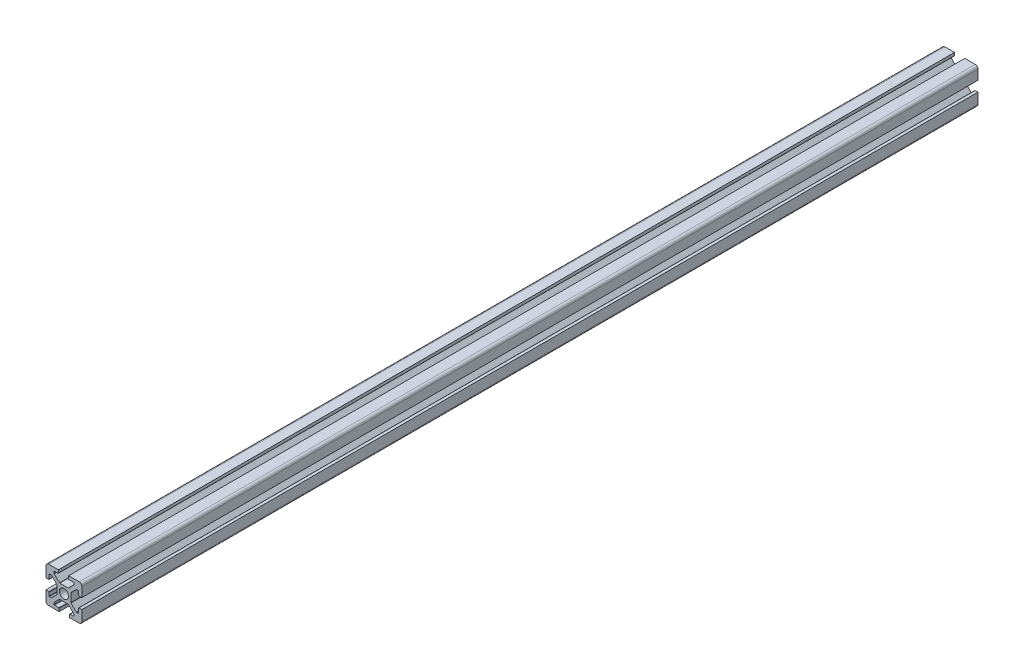
from build123d import *

# Parameters (mm, degrees)
SKETCH1_R           = 2.55
BOSS_EXTRUDE1_DEPTH = 500


with BuildPart() as part:
    # Sketch1 → Boss-Extrude1 (new body)
    with BuildSketch(Plane.XY):
        with BuildLine():
            Line((-8.5, -10), (-2.647623804, -10))
            Line((-2.647623804, -10), (-2.647623804, -8.45))
            ThreePointArc((-2.647623804, -8.45), (-2.720847109, -8.273223305), (-2.897623804, -8.2))
            Line((-2.897623804, -8.2), (-5.25, -8.2))
            ThreePointArc((-5.25, -8.2), (-5.426776695, -8.126776695), (-5.5, -7.95))
            Line((-5.5, -7.95), (-5.5, -7.053553391))
            ThreePointArc((-5.5, -7.053553391), (-5.480969883, -6.957882533), (-5.426776695, -6.876776695))
            Line((-5.426776695, -6.876776695), (-2.523223305, -3.973223305))
            ThreePointArc((-2.523223305, -3.973223305), (-2.442117467, -3.919030117), (-2.346446609, -3.9))
            Line((-2.346446609, -3.9), (2.346446609, -3.9))
            ThreePointArc((2.346446609, -3.9), (2.442117467, -3.919030117), (2.523223305, -3.973223305))
            Line((2.523223305, -3.973223305), (5.426776695, -6.876776695))
            ThreePointArc((5.426776695, -6.876776695), (5.480969883, -6.957882533), (5.5, -7.053553391))
            Line((5.5, -7.053553391), (5.5, -7.95))
            ThreePointArc((5.5, -7.95), (5.426776695, -8.126776695), (5.25, -8.2))
            Line((5.25, -8.2), (3.35, -8.2))
            ThreePointArc((3.35, -8.2), (3.173223305, -8.273223305), (3.1, -8.45))
            Line((3.1, -8.45), (3.1, -10))
            Line((3.1, -10), (8.5, -10))
            ThreePointArc((8.5, -10), (9.560660172, -9.560660172), (10, -8.5))
            Line((10, -8.5), (10, -2.647623804))
            Line((10, -2.647623804), (8.45, -2.647623804))
            ThreePointArc((8.45, -2.647623804), (8.273223305, -2.720847109), (8.2, -2.897623804))
            Line((8.2, -2.897623804), (8.2, -5.25))
            ThreePointArc((8.2, -5.25), (8.126776695, -5.426776695), (7.95, -5.5))
            Line((7.95, -5.5), (7.053553391, -5.5))
            ThreePointArc((7.053553391, -5.5), (6.957882533, -5.480969883), (6.876776695, -5.426776695))
            Line((6.876776695, -5.426776695), (3.973223305, -2.523223305))
            ThreePointArc((3.973223305, -2.523223305), (3.919030117, -2.442117467), (3.9, -2.346446609))
            Line((3.9, -2.346446609), (3.9, 2.346446609))
            ThreePointArc((3.9, 2.346446609), (3.919030117, 2.442117467), (3.973223305, 2.523223305))
            Line((3.973223305, 2.523223305), (6.876776695, 5.426776695))
            ThreePointArc((6.876776695, 5.426776695), (6.957882533, 5.480969883), (7.053553391, 5.5))
            Line((7.053553391, 5.5), (7.95, 5.5))
            ThreePointArc((7.95, 5.5), (8.126776695, 5.426776695), (8.2, 5.25))
            Line((8.2, 5.25), (8.2, 3.35))
            ThreePointArc((8.2, 3.35), (8.273223305, 3.173223305), (8.45, 3.1))
            Line((8.45, 3.1), (10, 3.1))
            Line((10, 3.1), (10, 8.5))
            ThreePointArc((10, 8.5), (9.560660172, 9.560660172), (8.5, 10))
            Line((8.5, 10), (2.647623804, 10))
            Line((2.647623804, 10), (2.647623804, 8.45))
            ThreePointArc((2.647623804, 8.45), (2.720847109, 8.273223305), (2.897623804, 8.2))
            Line((2.897623804, 8.2), (5.25, 8.2))
            ThreePointArc((5.25, 8.2), (5.426776695, 8.126776695), (5.5, 7.95))
            Line((5.5, 7.95), (5.5, 7.053553391))
            ThreePointArc((5.5, 7.053553391), (5.480969883, 6.957882533), (5.426776695, 6.876776695))
            Line((5.426776695, 6.876776695), (2.523223305, 3.973223305))
            ThreePointArc((2.523223305, 3.973223305), (2.442117467, 3.919030117), (2.346446609, 3.9))
            Line((2.346446609, 3.9), (-2.346446609, 3.9))
            ThreePointArc((-2.346446609, 3.9), (-2.442117467, 3.919030117), (-2.523223305, 3.973223305))
            Line((-2.523223305, 3.973223305), (-5.426776695, 6.876776695))
            ThreePointArc((-5.426776695, 6.876776695), (-5.480969883, 6.957882533), (-5.5, 7.053553391))
            Line((-5.5, 7.053553391), (-5.5, 7.95))
            ThreePointArc((-5.5, 7.95), (-5.426776695, 8.126776695), (-5.25, 8.2))
            Line((-5.25, 8.2), (-3.35, 8.2))
            ThreePointArc((-3.35, 8.2), (-3.173223305, 8.273223305), (-3.1, 8.45))
            Line((-3.1, 8.45), (-3.1, 10))
            Line((-3.1, 10), (-8.5, 10))
            ThreePointArc((-8.5, 10), (-9.560660172, 9.560660172), (-10, 8.5))
            Line((-10, 8.5), (-10, 2.647623804))
            Line((-10, 2.647623804), (-8.45, 2.647623804))
            ThreePointArc((-8.45, 2.647623804), (-8.273223305, 2.720847109), (-8.2, 2.897623804))
            Line((-8.2, 2.897623804), (-8.2, 5.25))
            ThreePointArc((-8.2, 5.25), (-8.126776695, 5.426776695), (-7.95, 5.5))
            Line((-7.95, 5.5), (-7.053553391, 5.5))
            ThreePointArc((-7.053553391, 5.5), (-6.957882533, 5.480969883), (-6.876776695, 5.426776695))
            Line((-6.876776695, 5.426776695), (-3.973223305, 2.523223305))
            ThreePointArc((-3.973223305, 2.523223305), (-3.919030117, 2.442117467), (-3.9, 2.346446609))
            Line((-3.9, 2.346446609), (-3.9, -2.346446609))
            ThreePointArc((-3.9, -2.346446609), (-3.919030117, -2.442117467), (-3.973223305, -2.523223305))
            Line((-3.973223305, -2.523223305), (-6.876776695, -5.426776695))
            ThreePointArc((-6.876776695, -5.426776695), (-6.957882533, -5.480969883), (-7.053553391, -5.5))
            Line((-7.053553391, -5.5), (-7.95, -5.5))
            ThreePointArc((-7.95, -5.5), (-8.126776695, -5.426776695), (-8.2, -5.25))
            Line((-8.2, -5.25), (-8.2, -3.35))
            ThreePointArc((-8.2, -3.35), (-8.273223305, -3.173223305), (-8.45, -3.1))
            Line((-8.45, -3.1), (-10, -3.1))
            Line((-10, -3.1), (-10, -8.5))
            ThreePointArc((-10, -8.5), (-9.560660172, -9.560660172), (-8.5, -10))
        make_face()
        Circle(SKETCH1_R, mode=Mode.SUBTRACT)
    extrude(amount=BOSS_EXTRUDE1_DEPTH)


solid = part.part
